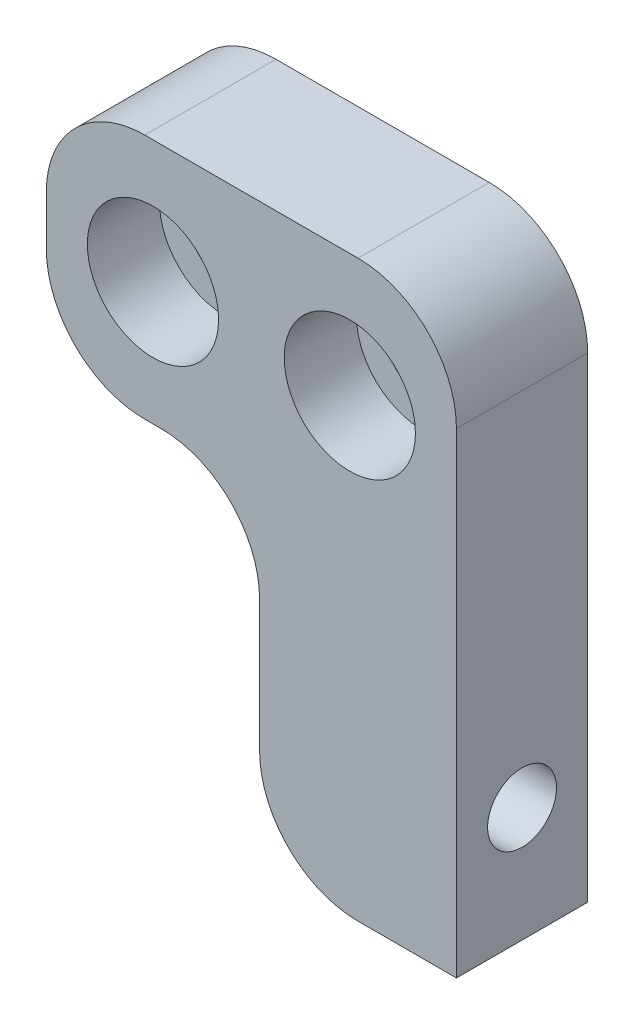
from build123d import *

# Parameters (mm, degrees)
EXTRUDE1_DEPTH                                      = 8
CBORE_FOR_M4_HEX_SOCKET_HEAD_CAP_SCREW1_D           = 4.5
CBORE_FOR_M4_HEX_SOCKET_HEAD_CAP_SCREW1_CBORE_D     = 8
CBORE_FOR_M4_HEX_SOCKET_HEAD_CAP_SCREW1_CBORE_DEPTH = 4.4
M5_TAPPED_HOLE1_D                                   = 4.2


with BuildPart() as part:
    # Sketch1 → Extrude1 (new body)
    with BuildSketch(Plane.XY):
        with BuildLine():
            Line((0, 6), (0, 14))
            ThreePointArc((0, 14), (-1.757359313, 18.242640687), (-6, 20))
            Line((-6, 20), (-7, 20))
            ThreePointArc((-7, 20), (-11.242640687, 21.757359313), (-13, 26))
            Line((-13, 26), (-13, 29))
            ThreePointArc((-13, 29), (-11.242640687, 33.242640687), (-7, 35))
            Line((-7, 35), (6, 35))
            ThreePointArc((6, 35), (10.242640687, 33.242640687), (12, 29))
            Line((12, 29), (12, 0))
            Line((12, 0), (6, 0))
            ThreePointArc((6, 0), (1.757359313, 1.757359313), (0, 6))
        make_face()
    extrude(amount=EXTRUDE1_DEPTH)

    # CBORE for M4 Hex Socket Head Cap Screw1 (through all)
    with Locations(Plane.XY.offset(8)):
        with Locations((-6.5, 27.5), (5.5, 27.5)):
            CounterBoreHole(CBORE_FOR_M4_HEX_SOCKET_HEAD_CAP_SCREW1_D / 2, CBORE_FOR_M4_HEX_SOCKET_HEAD_CAP_SCREW1_CBORE_D / 2, CBORE_FOR_M4_HEX_SOCKET_HEAD_CAP_SCREW1_CBORE_DEPTH)

    # M5 Tapped Hole1 (through all)
    with Locations(Plane(origin=(12, 0, 0), x_dir=(0, 0, -1), z_dir=(1, 0, 0))):
        with Locations((-4, 7)):
            Hole(M5_TAPPED_HOLE1_D / 2)


solid = part.part
